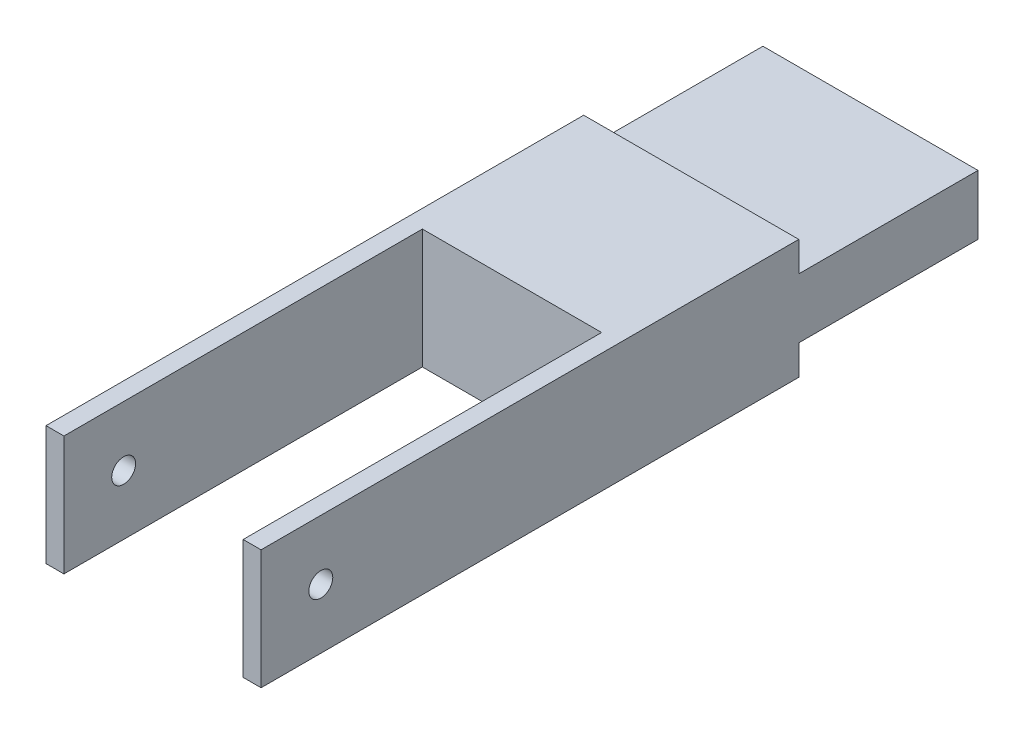
from build123d import *

# Parameters (mm, degrees)
SKETCH_1_W          = 36
SKETCH_1_H          = 120
EXTRUDE_1_DEPTH     = 20
SKETCH_2_W          = 30
SKETCH_2_H          = 76.64229125
CUT_EXTRUDE_1_DEPTH = 20
SKETCH_3_W          = 53.751349406
SKETCH_3_H          = 17.737070837
SKETCH_3_W_2        = 54.426052537
SKETCH_3_H_2        = 11.321534577
CUT_EXTRUDE_2_DEPTH = 30
SKETCH_5_R          = 2
CUT_EXTRUDE_3_DEPTH = 70


with BuildPart() as part:
    # 草图1 → 凸台-拉伸1 (new body)
    with BuildSketch(Plane(origin=(0, 0, 0), x_dir=(1, 0, 0), z_dir=(0, 1, 0))):
        Rectangle(SKETCH_1_W, SKETCH_1_H)
    extrude(amount=EXTRUDE_1_DEPTH)

    # 草图2 → 切除-拉伸1 (cut)
    with BuildSketch(Plane(origin=(0, 20, 0), x_dir=(1, 0, 0), z_dir=(0, 1, 0))):
        with Locations((0, -38.321145625)):
            Rectangle(SKETCH_2_W, SKETCH_2_H)
    extrude(amount=-CUT_EXTRUDE_1_DEPTH, mode=Mode.SUBTRACT)

    # 草图3 → 切除-拉伸2 (cut)
    with BuildSketch(Plane(origin=(0, 0, -60), x_dir=(-1, 0, 0), z_dir=(0, 0, -1))):
        with Locations((-0.187417536, -3.868535419)):
            Rectangle(SKETCH_3_W, SKETCH_3_H)
        with Locations((0.074967015, 20.660767289)):
            Rectangle(SKETCH_3_W_2, SKETCH_3_H_2)
    extrude(amount=-CUT_EXTRUDE_2_DEPTH, mode=Mode.SUBTRACT)

    # 草图5 → 切除-拉伸3 (cut)
    with BuildSketch(Plane(origin=(18, 0, 0), x_dir=(0, 0, -1), z_dir=(1, 0, 0))):
        with Locations((-50, 10)):
            Circle(SKETCH_5_R)
    extrude(amount=-CUT_EXTRUDE_3_DEPTH, mode=Mode.SUBTRACT)


solid = part.part
